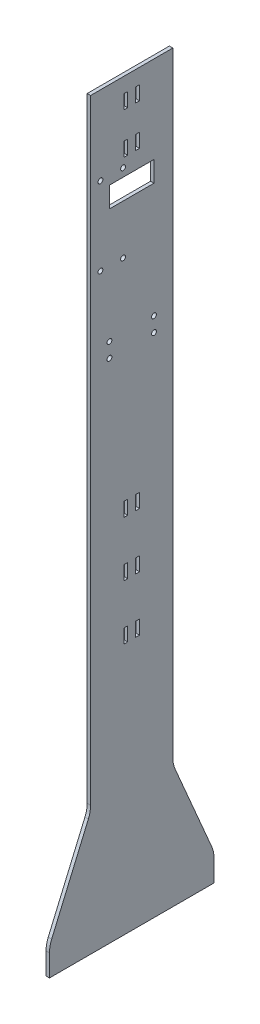
from build123d import *

# Parameters (mm, degrees)
SKETCH1_W                     = 76.2
SKETCH1_H                     = 914.4
BOSS_EXTRUDE1_DEPTH           = 3.175
SKETCH2_W                     = 3.556
SKETCH2_H                     = 12.954
CUT_EXTRUDE1_DEPTH            = 4.175
LPATTERN1_COUNT               = 2
LPATTERN1_PITCH               = 50.8
LPATTERN1_COPY_1_SKETCH_W     = 3.556
LPATTERN1_COPY_1_SKETCH_H     = 12.954
LPATTERN1_COPY_1_DEPTH        = 4.175
LPATTERN1_COL_COUNT           = 2
LPATTERN1_COL_PITCH           = 50.8
LPATTERN1_COL_COPY_1_SKETCH_W = 3.556
LPATTERN1_COL_COPY_1_SKETCH_H = 12.954
LPATTERN1_COL_COPY_1_DEPTH    = 4.175
SKETCH3_W                     = 3.556
SKETCH3_H                     = 12.954
CUT_EXTRUDE2_DEPTH            = 4.175
LPATTERN2_COUNT               = 2
LPATTERN2_PITCH               = 38.1
CUT_EXTRUDE3_DEPTH            = 4.175
SKETCH5_W                     = 76.2
SKETCH5_H                     = 44.45
BOSS_EXTRUDE2_DEPTH           = 3.175
SKETCH6_W                     = 41.275
SKETCH6_H                     = 19.05
CUT_EXTRUDE4_DEPTH            = 4.175
BOSS_EXTRUDE3_DEPTH           = 3.175
FILLET1_R                     = 25.4
F_8_CLEARANCE_HOLE1_D         = 4.4958


with BuildPart() as part:
    # Sketch1 → Boss-Extrude1 (new body)
    with BuildSketch(Plane(origin=(0, 0, 0), x_dir=(0, 0, -1), z_dir=(1, 0, 0))):
        Rectangle(SKETCH1_W, SKETCH1_H)
    extrude(amount=BOSS_EXTRUDE1_DEPTH)

    # Sketch2 → Cut-Extrude1 (cut, through all)
    with BuildSketch(Plane(origin=(3.175, 0, 0), x_dir=(0, 0, -1), z_dir=(1, 0, 0))):
        with Locations((5.499997, -211.0105)):
            Rectangle(SKETCH2_W, SKETCH2_H)
    cut_extrude1 = extrude(amount=-CUT_EXTRUDE1_DEPTH, mode=Mode.SUBTRACT)

    # Mirror1: Cut-Extrude1 across plane
    add(cut_extrude1.mirror(Plane.XY), mode=Mode.SUBTRACT)

    # LPattern1: Cut-Extrude1 ×2
    with Locations(*[(0, i * LPATTERN1_PITCH, 0) for i in range(1, LPATTERN1_COUNT)]):
        add(cut_extrude1, mode=Mode.SUBTRACT)

    # LPattern1 copy 1 sketch → LPattern1 copy 1 (cut, through all)
    with BuildSketch(Plane(origin=(3.175, 50.8, 0), x_dir=(0, 0, 1), z_dir=(1, 0, 0))):
        with Locations((5.499997, 211.0105)):
            Rectangle(LPATTERN1_COPY_1_SKETCH_W, LPATTERN1_COPY_1_SKETCH_H)
    extrude(amount=-LPATTERN1_COPY_1_DEPTH, mode=Mode.SUBTRACT)

    # LPattern1 col: Cut-Extrude1 ×2
    with Locations(*[(0, -i * LPATTERN1_COL_PITCH, 0) for i in range(1, LPATTERN1_COL_COUNT)]):
        add(cut_extrude1, mode=Mode.SUBTRACT)

    # LPattern1 col copy 1 sketch → LPattern1 col copy 1 (cut, through all)
    with BuildSketch(Plane(origin=(3.175, -50.8, 0), x_dir=(0, 0, 1), z_dir=(1, 0, 0))):
        with Locations((5.499997, 211.0105)):
            Rectangle(LPATTERN1_COL_COPY_1_SKETCH_W, LPATTERN1_COL_COPY_1_SKETCH_H)
    extrude(amount=-LPATTERN1_COL_COPY_1_DEPTH, mode=Mode.SUBTRACT)

    # Sketch3 → Cut-Extrude2 (cut, through all)
    with BuildSketch(Plane(origin=(3.175, 0, 0), x_dir=(0, 0, -1), z_dir=(1, 0, 0))):
        with Locations((5.499997, 128.7145)):
            Rectangle(SKETCH3_W, SKETCH3_H)
        with Locations((-5.499997, 128.7145)):
            Rectangle(SKETCH3_W, SKETCH3_H)
    cut_extrude2 = extrude(amount=-CUT_EXTRUDE2_DEPTH, mode=Mode.SUBTRACT)

    # LPattern2: Cut-Extrude2 ×2
    with Locations(*[(0, i * LPATTERN2_PITCH, 0) for i in range(1, LPATTERN2_COUNT)]):
        add(cut_extrude2, mode=Mode.SUBTRACT)

    # Sketch4 → Cut-Extrude3 (cut, through all)
    with BuildSketch(Plane(origin=(3.175, 0, 0), x_dir=(0, 0, -1), z_dir=(1, 0, 0))):
        Polygon((-38.1, 187.325), (0, 187.325), (38.1, 187.325), (38.1, 457.2), (-38.1, 457.2), align=None)
    extrude(amount=-CUT_EXTRUDE3_DEPTH, mode=Mode.SUBTRACT)

    # Sketch5 → Boss-Extrude2 (add)
    with BuildSketch(Plane(origin=(3.175, 0, 0), x_dir=(0, 0, -1), z_dir=(1, 0, 0))):
        with Locations((0, -479.425)):
            Rectangle(SKETCH5_W, SKETCH5_H)
    extrude(amount=-BOSS_EXTRUDE2_DEPTH)

    # Sketch6 → Cut-Extrude4 (cut, through all)
    with BuildSketch(Plane(origin=(3.175, 0, 0), x_dir=(0, 0, -1), z_dir=(1, 0, 0))):
        with Locations((0, 97.106805088)):
            Rectangle(SKETCH6_W, SKETCH6_H)
    extrude(amount=-CUT_EXTRUDE4_DEPTH, mode=Mode.SUBTRACT)

    # Sketch7 → Boss-Extrude3 (add)
    with BuildSketch(Plane(origin=(3.175, 0, 0), x_dir=(0, 0, -1), z_dir=(1, 0, 0))):
        Polygon((-76.2, -501.65), (76.2, -501.65), (76.2, -476.25), (38.1, -387.35), (-38.1, -387.35), (-76.2, -476.25), align=None)
    extrude(amount=-BOSS_EXTRUDE3_DEPTH)

    # Fillet1
    fillet1_edges = [part.edges().sort_by_distance(p)[0] for p in [
        (1.5875, -476.25, 76.2),
        (1.5875, -387.35, 38.1),
        (1.5875, -387.35, -38.1),
        (1.5875, -476.25, -76.2),
    ]]
    fillet(fillet1_edges, radius=FILLET1_R)

    # #8 Clearance Hole1 (through all)
    with Locations(Plane(origin=(3.175, 0, 0), x_dir=(0, 0, -1), z_dir=(1, 0, 0))):
        with Locations((-7.998961309, 41.861805088), (-28.953961309, 41.861805088), (20.6375, -18.825765594), (-20.6375, -18.825765594), (20.6375, -32.300765594), (-20.6375, -32.300765594), (-7.998961309, 114.251805088), (-28.953961309, 114.251805088)):
            Hole(F_8_CLEARANCE_HOLE1_D / 2)


solid = part.part
